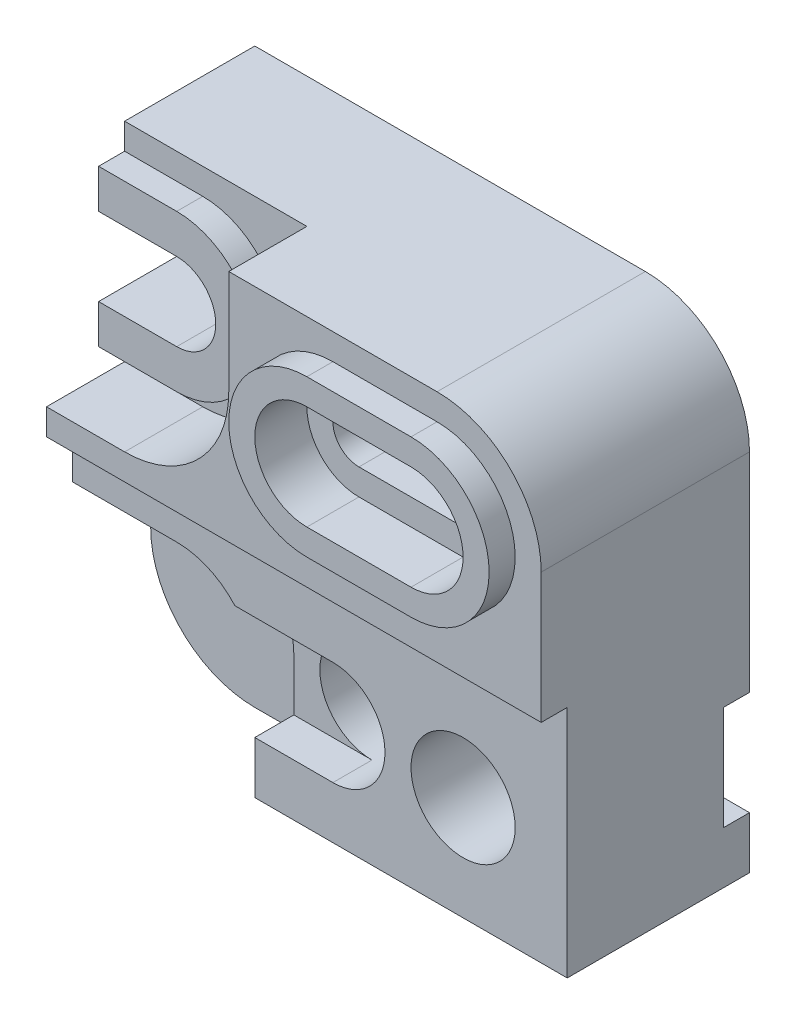
from build123d import *

# Parameters (mm, degrees)
SKETCH1_W           = 190
SKETCH1_H           = 180
BOSS_EXTRUDE1_DEPTH = 70
CUT_EXTRUDE1_DEPTH  = 70
CUT_EXTRUDE2_DEPTH  = 20
CUT_EXTRUDE4_DEPTH  = 116
CUT_EXTRUDE5_DEPTH  = 116
SKETCH6_W           = 20
SKETCH6_H           = 90
CUT_EXTRUDE6_DEPTH  = 242
BOSS_EXTRUDE2_DEPTH = 10
CUT_EXTRUDE12_DEPTH = 20
BOSS_EXTRUDE4_DEPTH = 10
BOSS_EXTRUDE5_DEPTH = 30
CUT_EXTRUDE13_DEPTH = 10
SKETCH15_W          = 190
SKETCH15_H          = 10
BOSS_EXTRUDE6_DEPTH = 30
CUT_EXTRUDE14_DEPTH = 30
BOSS_EXTRUDE7_DEPTH = 30
BOSS_EXTRUDE8_DEPTH = 10
CUT_EXTRUDE15_DEPTH = 20
CUT_EXTRUDE16_DEPTH = 62
CUT_EXTRUDE17_DEPTH = 30
CUT_EXTRUDE18_DEPTH = 15
SKETCH25_R          = 20
CUT_EXTRUDE19_DEPTH = 50
SKETCH26_R          = 10
CUT_EXTRUDE20_DEPTH = 20
CUT_EXTRUDE21_DEPTH = 20
SKETCH28_W          = 10
SKETCH28_H          = 40
CUT_EXTRUDE22_DEPTH = 59


with BuildPart() as part:
    # Sketch1 → Boss-Extrude1 (new body)
    with BuildSketch(Plane.XY):
        with Locations((95, 90)):
            Rectangle(SKETCH1_W, SKETCH1_H)
    extrude(amount=BOSS_EXTRUDE1_DEPTH)

    # Sketch2 → Cut-Extrude1 (cut)
    with BuildSketch(Plane(origin=(0, 0, 0), x_dir=(-1, 0, 0), z_dir=(0, 0, -1))):
        with BuildLine():
            Line((-150, 150), (-110, 150))
            ThreePointArc((-110, 150), (-100, 140), (-110, 130))
            Line((-110, 130), (-150, 130))
            ThreePointArc((-150, 130), (-160, 140), (-150, 150))
        make_face()
    extrude(amount=-CUT_EXTRUDE1_DEPTH, mode=Mode.SUBTRACT)

    # Sketch3 → Cut-Extrude2 (cut)
    with BuildSketch(Plane(origin=(0, 0, 0), x_dir=(-1, 0, 0), z_dir=(0, 0, -1))):
        with BuildLine():
            Line((-110, 120), (-150, 120))
            ThreePointArc((-150, 120), (-170, 140), (-150, 160))
            Line((-150, 160), (-110, 160))
            ThreePointArc((-110, 160), (-90, 140), (-110, 120))
        make_face()
    extrude(amount=-CUT_EXTRUDE2_DEPTH, mode=Mode.SUBTRACT)

    # Sketch4 → Cut-Extrude4 (cut)
    with BuildSketch(Plane.XY.offset(70)):
        with BuildLine():
            Line((150, 180), (190, 180))
            Line((190, 180), (190, 140))
            ThreePointArc((190, 140), (178.284271247, 168.284271247), (150, 180))
        make_face()
        with BuildLine():
            Line((0, 40), (0, 0))
            Line((0, 0), (40, 0))
            ThreePointArc((40, 0), (11.715728753, 11.715728753), (0, 40))
        make_face()
    extrude(amount=-CUT_EXTRUDE4_DEPTH, mode=Mode.SUBTRACT)

    # Sketch5 → Cut-Extrude5 (cut)
    with BuildSketch(Plane.XY.offset(70)):
        with BuildLine():
            Line((30, 155), (0, 155))
            Line((0, 155), (0, 125))
            Line((0, 125), (30, 125))
            ThreePointArc((30, 125), (45, 140), (30, 155))
        make_face()
    extrude(amount=-CUT_EXTRUDE5_DEPTH, mode=Mode.SUBTRACT)

    # Sketch6 → Cut-Extrude6 (cut)
    with BuildSketch(Plane.ZY):
        with Locations((60, 135)):
            Rectangle(SKETCH6_W, SKETCH6_H)
    extrude(amount=-CUT_EXTRUDE6_DEPTH, mode=Mode.SUBTRACT)

    # Sketch7 → Boss-Extrude2 (add)
    with BuildSketch(Plane.XY.offset(50)):
        with BuildLine():
            Line((150, 110), (110, 110))
            ThreePointArc((110, 110), (80, 140), (110, 170))
            Line((110, 170), (150, 170))
            ThreePointArc((150, 170), (180, 140), (150, 110))
        make_face()
    extrude(amount=BOSS_EXTRUDE2_DEPTH)

    # Sketch11 → Cut-Extrude12 (cut)
    with BuildSketch(Plane(origin=(0, 0, 50), x_dir=(-1, 0, 0), z_dir=(0, 0, -1))):
        with BuildLine():
            Line((-150, 150), (-110, 150))
            ThreePointArc((-110, 150), (-100, 140), (-110, 130))
            Line((-110, 130), (-150, 130))
            ThreePointArc((-150, 130), (-160, 140), (-150, 150))
        make_face()
    extrude(amount=-CUT_EXTRUDE12_DEPTH, mode=Mode.SUBTRACT)

    # Sketch12 → Boss-Extrude4 (add)
    with BuildSketch(Plane.XY.offset(50)):
        with BuildLine():
            Line((30, 155), (0, 155))
            Line((0, 155), (0, 170))
            Line((0, 170), (30, 170))
            ThreePointArc((30, 170), (60, 140), (30, 110))
            Line((30, 110), (0, 110))
            Line((0, 110), (0, 125))
            Line((0, 125), (30, 125))
            ThreePointArc((30, 125), (45, 140), (30, 155))
        make_face()
    extrude(amount=BOSS_EXTRUDE4_DEPTH)

    # Sketch13 → Boss-Extrude5 (add)
    with BuildSketch(Plane.XY.offset(50)):
        with BuildLine():
            Line((150, 180), (0, 180))
            Line((0, 180), (0, 170))
            Line((0, 170), (30, 170))
            ThreePointArc((30, 170), (60, 140), (30, 110))
            Line((30, 110), (0, 110))
            Line((0, 110), (0, 100))
            Line((0, 100), (190, 100))
            Line((190, 100), (190, 140))
            ThreePointArc((190, 140), (178.284271247, 168.284271247), (150, 180))
        make_face()
        with BuildLine():
            ThreePointArc((110, 110), (80, 140), (110, 170))
            Line((110, 170), (150, 170))
            ThreePointArc((150, 170), (180, 140), (150, 110))
            Line((150, 110), (110, 110))
        make_face(mode=Mode.SUBTRACT)
    extrude(amount=BOSS_EXTRUDE5_DEPTH)

    # Sketch14 → Cut-Extrude13 (cut)
    with BuildSketch(Plane.XY.offset(60)):
        with BuildLine():
            Line((110, 170), (150, 170))
            ThreePointArc((150, 170), (180, 140), (150, 110))
            Line((150, 110), (110, 110))
            ThreePointArc((110, 110), (80, 140), (110, 170))
        make_face()
    extrude(amount=-CUT_EXTRUDE13_DEPTH, mode=Mode.SUBTRACT)

    # Sketch15 → Boss-Extrude6 (add)
    with BuildSketch(Plane.XY.offset(50)):
        with Locations((95, 95)):
            Rectangle(SKETCH15_W, SKETCH15_H)
    extrude(amount=BOSS_EXTRUDE6_DEPTH)

    # Sketch16 → Cut-Extrude14 (cut)
    with BuildSketch(Plane.XY.offset(80)):
        with BuildLine():
            Line((0, 180), (0, 170))
            Line((0, 170), (30, 170))
            ThreePointArc((30, 170), (60, 140), (30, 110))
            Line((30, 110), (0, 110))
            Line((0, 110), (0, 100))
            Line((0, 100), (30, 100))
            ThreePointArc((30, 100), (58.284271247, 111.715728753), (70, 140))
            Line((70, 140), (70, 180))
            Line((70, 180), (0, 180))
        make_face()
    extrude(amount=-CUT_EXTRUDE14_DEPTH, mode=Mode.SUBTRACT)

    # Sketch18 → Boss-Extrude7 (add)
    with BuildSketch(Plane.XY.offset(50)):
        with BuildLine():
            Line((150, 110), (110, 110))
            ThreePointArc((110, 110), (80, 140), (110, 170))
            Line((110, 170), (150, 170))
            ThreePointArc((150, 170), (180, 140), (150, 110))
        make_face()
    extrude(amount=BOSS_EXTRUDE7_DEPTH)

    # Sketch20 → Boss-Extrude8 (add)
    with BuildSketch(Plane.XY.offset(80)):
        with BuildLine():
            Line((110, 170), (150, 170))
            ThreePointArc((150, 170), (180, 140), (150, 110))
            Line((150, 110), (110, 110))
            ThreePointArc((110, 110), (80, 140), (110, 170))
        make_face()
    extrude(amount=BOSS_EXTRUDE8_DEPTH)

    # Sketch21 → Cut-Extrude15 (cut)
    with BuildSketch(Plane.XY.offset(90)):
        with BuildLine():
            Line((110, 160), (150, 160))
            ThreePointArc((150, 160), (170, 140), (150, 120))
            Line((150, 120), (110, 120))
            ThreePointArc((110, 120), (90, 140), (110, 160))
        make_face()
    extrude(amount=-CUT_EXTRUDE15_DEPTH, mode=Mode.SUBTRACT)

    # Sketch22 → Cut-Extrude16 (cut)
    with BuildSketch(Plane(origin=(0, 0, 50), x_dir=(-1, 0, 0), z_dir=(0, 0, -1))):
        with BuildLine():
            Line((-150, 150), (-110, 150))
            ThreePointArc((-110, 150), (-100, 140), (-110, 130))
            Line((-110, 130), (-150, 130))
            ThreePointArc((-150, 130), (-160, 140), (-150, 150))
        make_face()
    extrude(amount=-CUT_EXTRUDE16_DEPTH, mode=Mode.SUBTRACT)

    # Sketch23 → Cut-Extrude17 (cut)
    with BuildSketch(Plane.XY.offset(70)):
        with BuildLine():
            Line((0, 40), (0, 70))
            Line((0, 70), (40, 70))
            ThreePointArc((40, 70), (61.213203436, 61.213203436), (70, 40))
            Line((70, 40), (70, 0))
            Line((70, 0), (40, 0))
            ThreePointArc((40, 0), (11.715728753, 11.715728753), (0, 40))
        make_face()
    extrude(amount=-CUT_EXTRUDE17_DEPTH, mode=Mode.SUBTRACT)

    # Sketch24 → Cut-Extrude18 (cut)
    with BuildSketch(Plane.XY.offset(70)):
        with BuildLine():
            ThreePointArc((100, 20), (80, 40), (100, 60))
            Line((100, 60), (62.360679775, 60))
            ThreePointArc((62.360679775, 60), (68.025170769, 50.704662693), (70, 40))
            Line((70, 40), (70, 20))
            Line((70, 20), (100, 20))
        make_face()
    extrude(amount=-CUT_EXTRUDE18_DEPTH, mode=Mode.SUBTRACT)

    # Sketch25 → Cut-Extrude19 (cut)
    with BuildSketch(Plane.XY.offset(70)):
        with Locations((100, 40)):
            Circle(SKETCH25_R)
        with Locations((150, 40)):
            Circle(SKETCH25_R)
    extrude(amount=-CUT_EXTRUDE19_DEPTH, mode=Mode.SUBTRACT)

    # Sketch26 → Cut-Extrude20 (cut)
    with BuildSketch(Plane.XY.offset(40)):
        with Locations((40, 40)):
            Circle(SKETCH26_R)
    extrude(amount=-CUT_EXTRUDE20_DEPTH, mode=Mode.SUBTRACT)

    # Sketch27 → Cut-Extrude21 (cut)
    with BuildSketch(Plane(origin=(0, 0, 0), x_dir=(-1, 0, 0), z_dir=(0, 0, -1))):
        with BuildLine():
            Line((0, 40), (0, 70))
            Line((0, 70), (-150, 70))
            ThreePointArc((-150, 70), (-180, 40), (-150, 10))
            Line((-150, 10), (-13.542486889, 10))
            ThreePointArc((-13.542486889, 10), (-3.542486889, 23.542486889), (0, 40))
        make_face()
    extrude(amount=-CUT_EXTRUDE21_DEPTH, mode=Mode.SUBTRACT)

    # Sketch28 → Cut-Extrude22 (cut)
    with BuildSketch(Plane(origin=(190, 0, 0), x_dir=(0, 0, -1), z_dir=(1, 0, 0))):
        with Locations((-5, 40)):
            Rectangle(SKETCH28_W, SKETCH28_H)
    extrude(amount=-CUT_EXTRUDE22_DEPTH, mode=Mode.SUBTRACT)


solid = part.part
